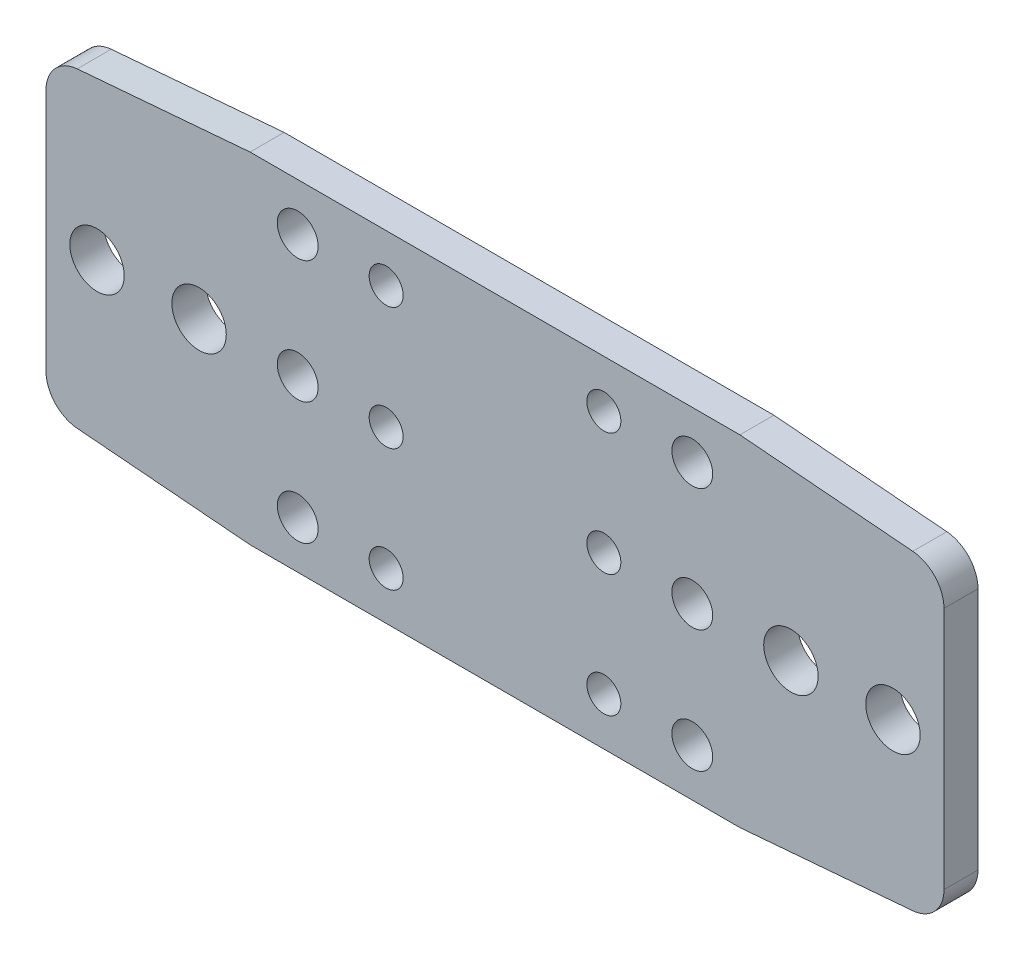
from build123d import *

# Parameters (mm, degrees)
SKETCH1_R           = 4
SKETCH1_R_2         = 2.5
SKETCH1_R_3         = 3
BOSS_EXTRUDE1_DEPTH = 5
FILLET1_R           = 5


with BuildPart() as part:
    # Sketch1 → Boss-Extrude1 (new body)
    with BuildSketch(Plane.XY):
        Polygon((72, 0), (0, 0), (-30, -2.5), (-30, -47.5), (0, -50), (72, -50), (102, -47.5), (102, -2.5), align=None)
        with Locations((-22.5, -25)):
            Circle(SKETCH1_R, mode=Mode.SUBTRACT)
        with Locations((-7.5, -25)):
            Circle(SKETCH1_R, mode=Mode.SUBTRACT)
        with Locations((52, -43)):
            Circle(SKETCH1_R_2, mode=Mode.SUBTRACT)
        with Locations((52, -7)):
            Circle(SKETCH1_R_2, mode=Mode.SUBTRACT)
        with Locations((79.5, -25)):
            Circle(SKETCH1_R, mode=Mode.SUBTRACT)
        with Locations((94.5, -25)):
            Circle(SKETCH1_R, mode=Mode.SUBTRACT)
        with Locations((20, -25)):
            Circle(SKETCH1_R_2, mode=Mode.SUBTRACT)
        with Locations((52, -25)):
            Circle(SKETCH1_R_2, mode=Mode.SUBTRACT)
        with Locations((7, -25)):
            Circle(SKETCH1_R_3, mode=Mode.SUBTRACT)
        with Locations((65, -25)):
            Circle(SKETCH1_R_3, mode=Mode.SUBTRACT)
        with Locations((20, -7)):
            Circle(SKETCH1_R_2, mode=Mode.SUBTRACT)
        with Locations((20, -43)):
            Circle(SKETCH1_R_2, mode=Mode.SUBTRACT)
        with BuildLine():
            ThreePointArc((7, -40), (4, -43), (7, -46))
            ThreePointArc((7, -46), (10, -43), (7, -40))
        make_face(mode=Mode.SUBTRACT)
        with BuildLine():
            ThreePointArc((65, -46), (68, -43), (65, -40))
            ThreePointArc((65, -40), (62, -43), (65, -46))
        make_face(mode=Mode.SUBTRACT)
        with BuildLine():
            ThreePointArc((65, -10), (68, -7), (65, -4))
            ThreePointArc((65, -4), (62, -7), (65, -10))
        make_face(mode=Mode.SUBTRACT)
        with BuildLine():
            ThreePointArc((7, -10), (10, -7), (7, -4))
            ThreePointArc((7, -4), (4, -7), (7, -10))
        make_face(mode=Mode.SUBTRACT)
    extrude(amount=BOSS_EXTRUDE1_DEPTH)

    # Fillet1
    fillet1_edges = [part.edges().sort_by_distance(p)[0] for p in [
        (102, -2.5, 2.5),
        (102, -47.5, 2.5),
        (-30, -47.5, 2.5),
        (-30, -2.5, 2.5),
    ]]
    fillet(fillet1_edges, radius=FILLET1_R)


solid = part.part
